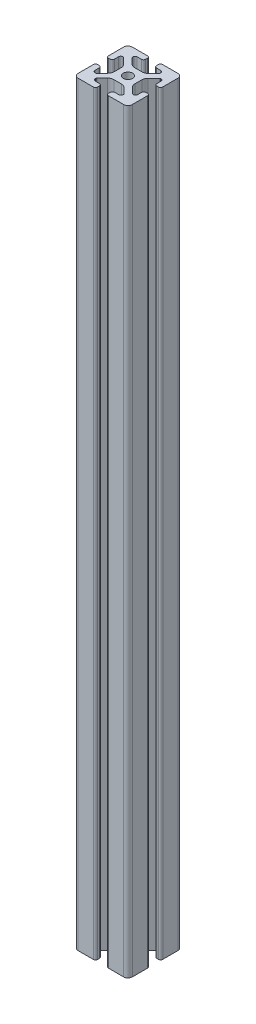
from build123d import *

# Parameters (mm, degrees)
SKETCH11_R               = 3.4
F_40_SERIES_4040_1_DEPTH = 558.8


with BuildPart() as part:
    # Sketch11 → 40 series 4040(1) (new body)
    with BuildSketch(Plane(origin=(0, 0, 0), x_dir=(-1, 0, 0), z_dir=(0, 1, 0))):
        with BuildLine():
            Line((-5.63, -15.524615034), (-8.715, -15.524615034))
            ThreePointArc((-8.715, -15.524615034), (-9.825157646, -15.06477268), (-10.285, -13.954615034))
            Line((-10.285, -13.954615034), (-10.285, -13.492503602))
            ThreePointArc((-10.285, -13.492503602), (-10.227148445, -13.201664194), (-10.062401154, -12.955102448))
            Line((-10.062401154, -12.955102448), (-6.217092793, -9.109794088))
            ThreePointArc((-6.217092793, -9.109794088), (-4.63891877, -8.055291919), (-2.777335583, -7.685))
            Line((-2.777335583, -7.685), (2.777335583, -7.685))
            ThreePointArc((2.777335583, -7.685), (4.63891877, -8.055291919), (6.217092793, -9.109794088))
            Line((6.217092793, -9.109794088), (10.062401154, -12.955102448))
            ThreePointArc((10.062401154, -12.955102448), (10.227148445, -13.201664194), (10.285, -13.492503602))
            Line((10.285, -13.492503602), (10.285, -13.954615034))
            ThreePointArc((10.285, -13.954615034), (9.825157646, -15.06477268), (8.715, -15.524615034))
            Line((8.715, -15.524615034), (5.63, -15.524615034))
            ThreePointArc((5.63, -15.524615034), (4.519842354, -15.984457388), (4.06, -17.094615034))
            Line((4.06, -17.094615034), (4.06, -18.43))
            ThreePointArc((4.06, -18.43), (4.519842354, -19.540157646), (5.63, -20))
            Line((5.63, -20), (16.83, -20))
            ThreePointArc((16.83, -20), (19.071528496, -19.071528496), (20, -16.83))
            Line((20, -16.83), (20, -5.63))
            ThreePointArc((20, -5.63), (19.540157461, -4.519842693), (18.43, -4.060000526))
            Line((18.43, -4.060000526), (17.24999625, -4.060000526))
            ThreePointArc((17.24999625, -4.060000526), (16.139838603, -4.519842879), (15.67999625, -5.630000526))
            Line((15.67999625, -5.630000526), (15.67999625, -8.715399492))
            ThreePointArc((15.67999625, -8.715399492), (15.220153896, -9.825557139), (14.10999625, -10.285399492))
            Line((14.10999625, -10.285399492), (13.6200547, -10.285399492))
            ThreePointArc((13.6200547, -10.285399492), (13.35903797, -10.160433474), (13.163657296, -9.946956002))
            Line((13.163657296, -9.946956002), (9.076242789, -5.859541495))
            ThreePointArc((9.076242789, -5.859541495), (8.046572221, -4.318530588), (7.685, -2.500784284))
            Line((7.685, -2.500784284), (7.685, 2.500784284))
            ThreePointArc((7.685, 2.500784284), (8.046572221, 4.318530588), (9.076242789, 5.859541495))
            Line((9.076242789, 5.859541495), (13.279501941, 10.062800646))
            ThreePointArc((13.279501941, 10.062800646), (13.526063686, 10.227547937), (13.816903094, 10.285399492))
            Line((13.816903094, 10.285399492), (14.10999625, 10.285399492))
            ThreePointArc((14.10999625, 10.285399492), (15.220153896, 9.825557139), (15.67999625, 8.715399492))
            Line((15.67999625, 8.715399492), (15.67999625, 5.630000526))
            ThreePointArc((15.67999625, 5.630000526), (16.139838603, 4.519842879), (17.24999625, 4.060000526))
            Line((17.24999625, 4.060000526), (18.43, 4.060000526))
            ThreePointArc((18.43, 4.060000526), (19.540157461, 4.519842693), (20, 5.63))
            Line((20, 5.63), (20, 16.83))
            ThreePointArc((20, 16.83), (19.071528496, 19.071528496), (16.83, 20))
            Line((16.83, 20), (5.63, 20))
            ThreePointArc((5.63, 20), (4.519842354, 19.540157646), (4.06, 18.43))
            Line((4.06, 18.43), (4.06, 17.094615034))
            ThreePointArc((4.06, 17.094615034), (4.519842354, 15.984457388), (5.63, 15.524615034))
            Line((5.63, 15.524615034), (8.715, 15.524615034))
            ThreePointArc((8.715, 15.524615034), (9.825157646, 15.06477268), (10.285, 13.954615034))
            Line((10.285, 13.954615034), (10.285, 13.492503602))
            ThreePointArc((10.285, 13.492503602), (10.227148445, 13.201664194), (10.062401154, 12.955102448))
            Line((10.062401154, 12.955102448), (6.217092793, 9.109794088))
            ThreePointArc((6.217092793, 9.109794088), (4.63891877, 8.055291919), (2.777335583, 7.685))
            Line((2.777335583, 7.685), (-2.777335583, 7.685))
            ThreePointArc((-2.777335583, 7.685), (-4.63891877, 8.055291919), (-6.217092793, 9.109794088))
            Line((-6.217092793, 9.109794088), (-10.062401154, 12.955102448))
            ThreePointArc((-10.062401154, 12.955102448), (-10.227148445, 13.201664194), (-10.285, 13.492503602))
            Line((-10.285, 13.492503602), (-10.285, 13.954615034))
            ThreePointArc((-10.285, 13.954615034), (-9.825157646, 15.06477268), (-8.715, 15.524615034))
            Line((-8.715, 15.524615034), (-5.63, 15.524615034))
            ThreePointArc((-5.63, 15.524615034), (-4.519842354, 15.984457388), (-4.06, 17.094615034))
            Line((-4.06, 17.094615034), (-4.06, 18.43))
            ThreePointArc((-4.06, 18.43), (-4.519842354, 19.540157646), (-5.63, 20))
            Line((-5.63, 20), (-16.83, 20))
            ThreePointArc((-16.83, 20), (-19.071528496, 19.071528496), (-20, 16.83))
            Line((-20, 16.83), (-20, 5.572979049))
            ThreePointArc((-20, 5.572979049), (-19.540157646, 4.462821403), (-18.43, 4.002979049))
            Line((-18.43, 4.002979049), (-17.25, 4.002979049))
            ThreePointArc((-17.25, 4.002979049), (-16.139842354, 4.462821403), (-15.68, 5.572979049))
            Line((-15.68, 5.572979049), (-15.68, 8.475666998))
            ThreePointArc((-15.68, 8.475666998), (-15.200613642, 9.605030484), (-14.05520779, 10.044710596))
            Line((-14.05520779, 10.044710596), (-13.71989919, 10.033001362))
            ThreePointArc((-13.71989919, 10.033001362), (-13.354224618, 10.012729352), (-13.040489136, 9.823787841))
            Line((-13.040489136, 9.823787841), (-9.076242789, 5.859541495))
            ThreePointArc((-9.076242789, 5.859541495), (-8.046572221, 4.318530588), (-7.685, 2.500784284))
            Line((-7.685, 2.500784284), (-7.685, -2.500784284))
            ThreePointArc((-7.685, -2.500784284), (-8.046572221, -4.318530588), (-9.076242789, -5.859541495))
            Line((-9.076242789, -5.859541495), (-13.279501941, -10.062800646))
            ThreePointArc((-13.279501941, -10.062800646), (-13.526061711, -10.227547119), (-13.816898819, -10.285399492))
            Line((-13.816898819, -10.285399492), (-14.10999625, -10.285399492))
            ThreePointArc((-14.10999625, -10.285399492), (-15.220153896, -9.825557139), (-15.67999625, -8.715399492))
            Line((-15.67999625, -8.715399492), (-15.67999625, -5.757919334))
            ThreePointArc((-15.67999625, -5.757919334), (-16.115287682, -4.60388249), (-17.25, -4.120449326))
            Line((-17.25, -4.120449326), (-18.43, -4.120449326))
            ThreePointArc((-18.43, -4.120449326), (-19.564709668, -4.603883664), (-20, -5.757918808))
            Line((-20, -5.757918808), (-20, -17.018368134))
            ThreePointArc((-20, -17.018368134), (-18.951578385, -19.194274381), (-16.674615034, -20))
            Line((-16.674615034, -20), (-5.63, -20))
            ThreePointArc((-5.63, -20), (-4.519842354, -19.540157646), (-4.06, -18.43))
            Line((-4.06, -18.43), (-4.06, -17.094615034))
            ThreePointArc((-4.06, -17.094615034), (-4.519842354, -15.984457388), (-5.63, -15.524615034))
        make_face()
        Circle(SKETCH11_R, mode=Mode.SUBTRACT)
    extrude(amount=F_40_SERIES_4040_1_DEPTH)


solid = part.part
